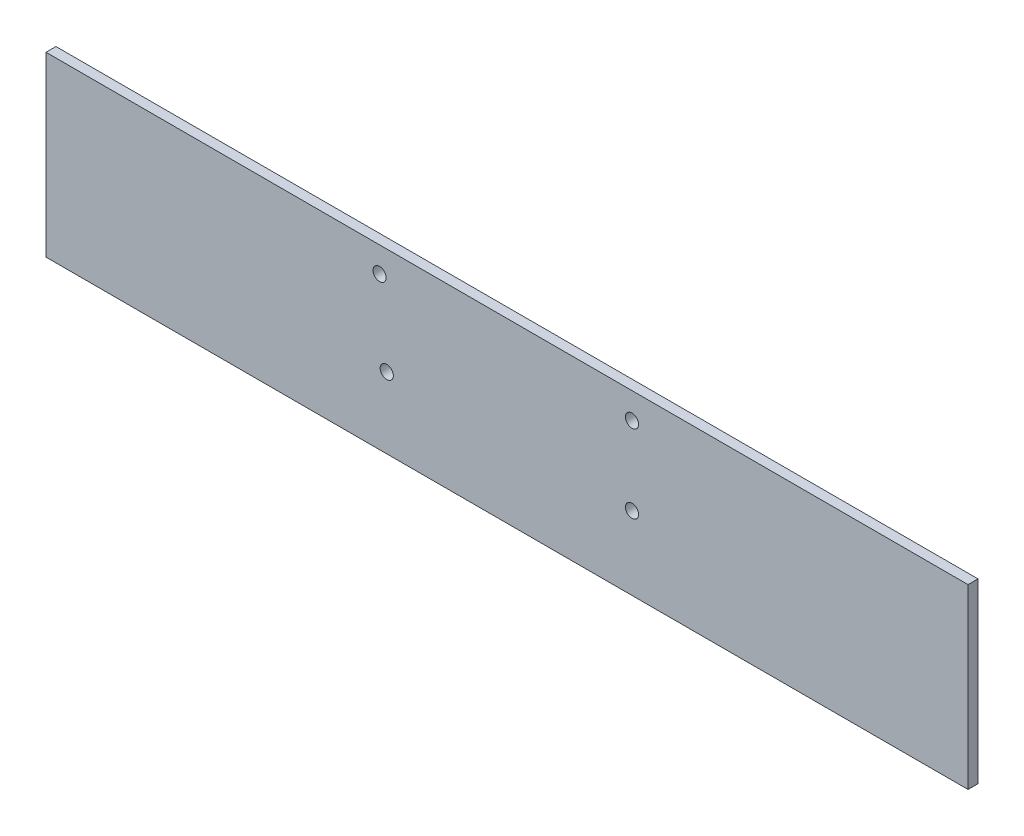
from build123d import *

# Parameters (mm, degrees)
SKETCH1_W           = 294.13016612
SKETCH1_H           = 56.59882
BOSS_EXTRUDE1_DEPTH = 3.175
SKETCH2_R           = 2.1
CUT_EXTRUDE1_DEPTH  = 4.175


with BuildPart() as part:
    # Sketch1 → Boss-Extrude1 (new body)
    with BuildSketch(Plane.XY):
        with Locations((157.553024493, 111.210577818)):
            Rectangle(SKETCH1_W, SKETCH1_H)
    extrude(amount=BOSS_EXTRUDE1_DEPTH)

    # Sketch2 → Cut-Extrude1 (cut, through all)
    with BuildSketch(Plane.XY.offset(3.175)):
        with Locations((197.417545464, 131.201988784)):
            Circle(SKETCH2_R)
        with Locations((116.899545441, 131.455981745)):
            Circle(SKETCH2_R)
        with Locations((119.185547706, 105.547981945)):
            Circle(SKETCH2_R)
        with Locations((197.41754764, 106.309988784)):
            Circle(SKETCH2_R)
    extrude(amount=-CUT_EXTRUDE1_DEPTH, mode=Mode.SUBTRACT)


solid = part.part
